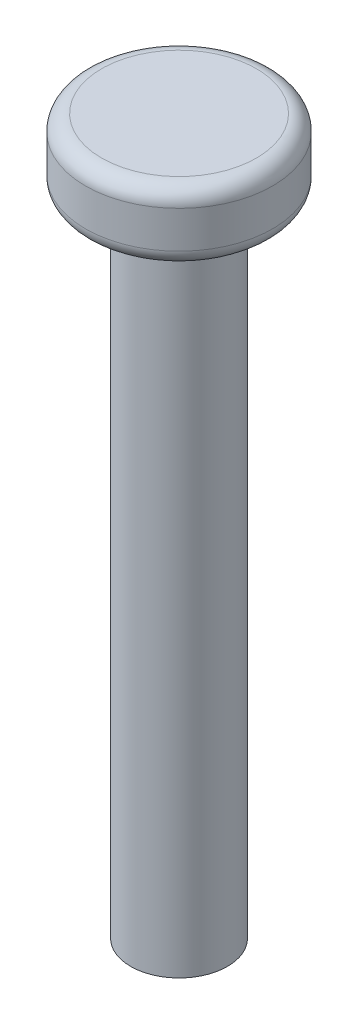
from build123d import *

# Parameters (mm, degrees)
SKETCH1_R           = 3
BOSS_EXTRUDE1_DEPTH = 40
SKETCH2_R           = 5.8
BOSS_EXTRUDE2_DEPTH = 4.3
FILLET1_R           = 1


with BuildPart() as part:
    # Sketch1 → Boss-Extrude1 (new body)
    with BuildSketch(Plane(origin=(0, 0, 0), x_dir=(1, 0, 0), z_dir=(0, 1, 0))):
        with Locations(Location((0, 0, 0), (0, 0, 270))):  # turned: the seam where the file's is
            Circle(SKETCH1_R)
    extrude(amount=BOSS_EXTRUDE1_DEPTH)

    # Sketch2 → Boss-Extrude2 (add)
    with BuildSketch(Plane(origin=(0, 40, 0), x_dir=(1, 0, 0), z_dir=(0, 1, 0))):
        with Locations(Location((0, 0, 0), (0, 0, 270))):  # turned: the seam where the file's is
            Circle(SKETCH2_R)
    extrude(amount=BOSS_EXTRUDE2_DEPTH)

    # Fillet1
    fillet1_edges = [part.edges().sort_by_distance(p)[0] for p in [
        (0, 40, -5.8),
        (0, 44.3, -5.8),
    ]]
    fillet(fillet1_edges, radius=FILLET1_R)


solid = part.part
